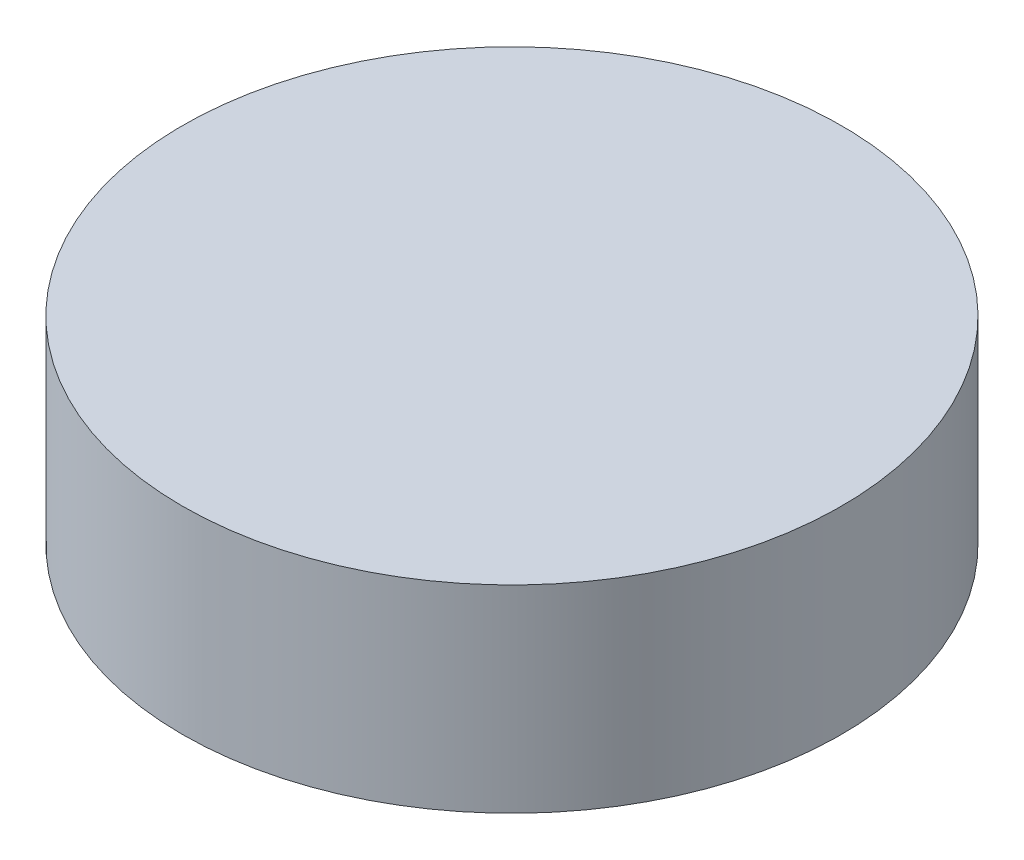
from build123d import *

# Parameters (mm, degrees)
SKETCH2_R           = 10
BOSS_EXTRUDE1_DEPTH = 3
SKETCH4_R           = 3
CUT_EXTRUDE2_DEPTH  = 3


with BuildPart() as part:
    # Sketch2 → Boss-Extrude1 (new body, symmetric)
    with BuildSketch(Plane(origin=(0, 0, 0), x_dir=(1, 0, 0), z_dir=(0, 1, 0))):
        Circle(SKETCH2_R)
    extrude(amount=BOSS_EXTRUDE1_DEPTH, both=True)

    # Sketch4 → Cut-Extrude2 (cut)
    with BuildSketch(Plane(origin=(0, -3, 0), x_dir=(-1, 0, 0), z_dir=(0, -1, 0))):
        Circle(SKETCH4_R)
    extrude(amount=-CUT_EXTRUDE2_DEPTH, mode=Mode.SUBTRACT)


solid = part.part
